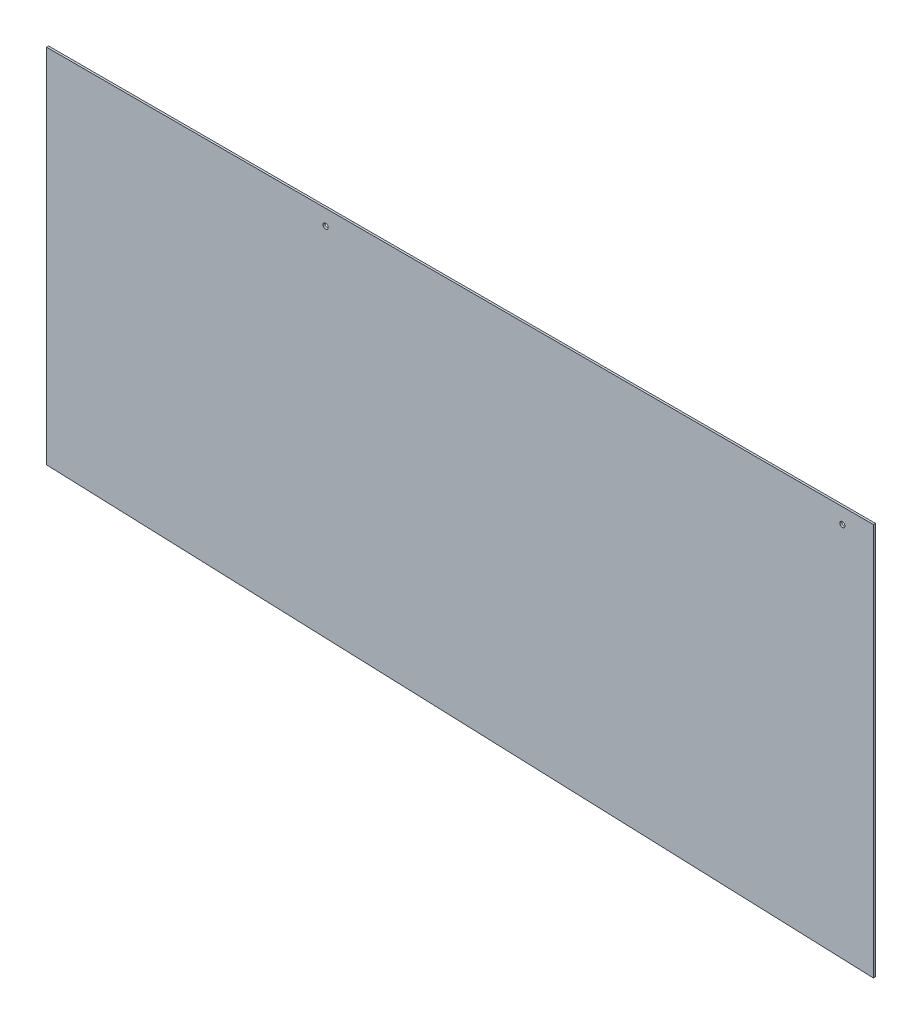
from build123d import *

# Parameters (mm, degrees)
SKETCH1_W           = 80
SKETCH1_H           = 35
SKETCH1_R           = 0.25
BOSS_EXTRUDE4_DEPTH = 0.2
BOSS_EXTRUDE5_DEPTH = 0.2


with BuildPart() as part:
    # Sketch1 → Boss-Extrude4 (new body)
    with BuildSketch(Plane.XY):
        with Locations((8.187411056, -3.455555556)):
            Rectangle(SKETCH1_W, SKETCH1_H)
        with Locations((-4.812588944, 12.544444444)):
            Circle(SKETCH1_R, mode=Mode.SUBTRACT)
        with Locations((45.187411056, 12.544444444)):
            Circle(SKETCH1_R, mode=Mode.SUBTRACT)
    extrude(amount=BOSS_EXTRUDE4_DEPTH)

    # Sketch3 → Boss-Extrude5 (add)
    with BuildSketch(Plane.XY.offset(0.2)):
        Polygon((-31.812588944, -20.955555556), (48.187411056, -23.955555556), (48.187411056, -20.955555556), align=None)
    extrude(amount=-BOSS_EXTRUDE5_DEPTH)


solid = part.part
